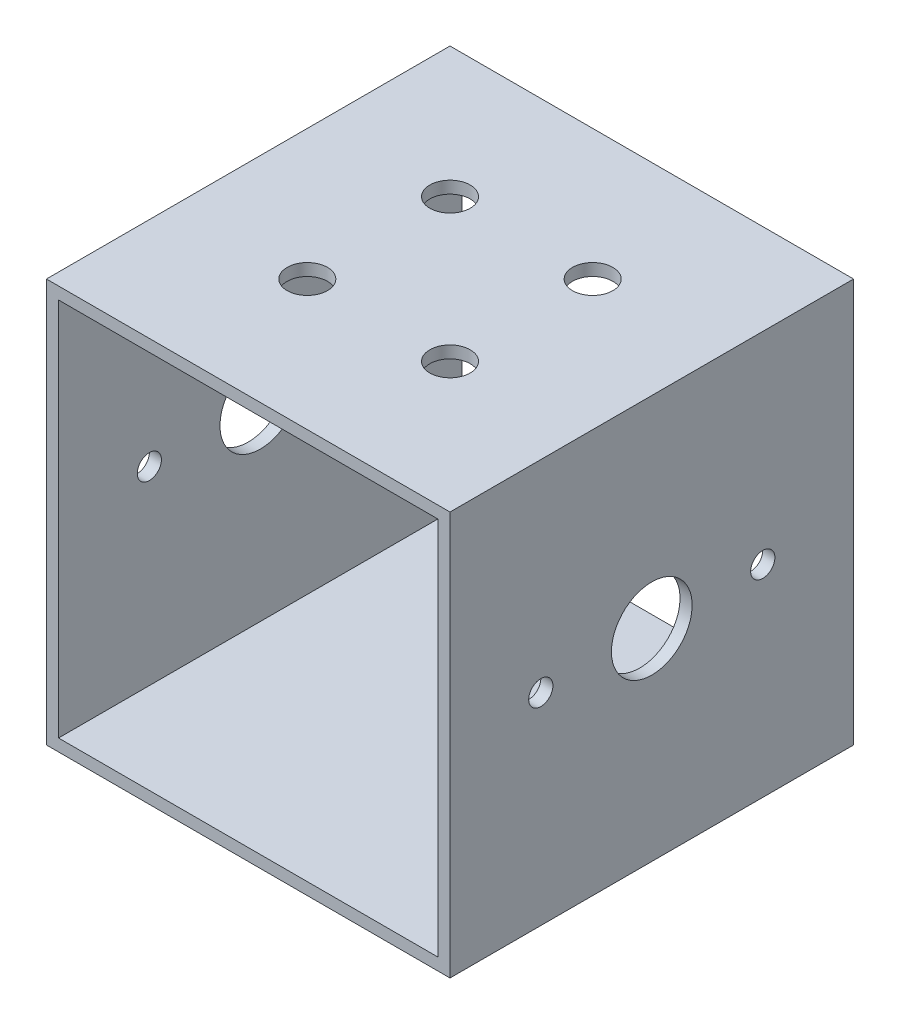
from build123d import *

# Parameters (mm, degrees)
ESBO_O1_W                  = 50
ESBO_O1_H                  = 50
ESBO_O1_W_2                = 47
ESBO_O1_H_2                = 47
RESSALTO_EXTRUS_O1_DEPTH   = 50
ESBO_O3_R                  = 5
CORTE_EXTRUS_O1_DEPTH      = 1
CORTE_EXTRUS_O1_DEPTH_BACK = 51
ESBO_O2_R                  = 2.5
CORTE_EXTRUS_O2_DEPTH      = 10
ESBO_O5_R                  = 1.5
CORTE_EXTRUS_O3_DEPTH      = 1
CORTE_EXTRUS_O3_DEPTH_BACK = 51


with BuildPart() as part:
    # Esboço1 → Ressalto-extrusão1 (new body)
    with BuildSketch(Plane.XY):
        Rectangle(ESBO_O1_W, ESBO_O1_H)
        Rectangle(ESBO_O1_W_2, ESBO_O1_H_2, mode=Mode.SUBTRACT)
    extrude(amount=RESSALTO_EXTRUS_O1_DEPTH)

    # Esboço3 → Corte-extrusão1 (cut, two sides)
    with BuildSketch(Plane(origin=(25, 0, 0), x_dir=(0, 0, -1), z_dir=(1, 0, 0))) as corte_extrus_o1_sk:
        with Locations((-25, 0)):
            Circle(ESBO_O3_R)
    extrude(amount=CORTE_EXTRUS_O1_DEPTH, mode=Mode.SUBTRACT)
    extrude(corte_extrus_o1_sk.sketch, amount=-CORTE_EXTRUS_O1_DEPTH_BACK, mode=Mode.SUBTRACT)

    # Esboço2 → Corte-extrusão2 (cut)
    with BuildSketch(Plane(origin=(0, 25, 0), x_dir=(1, 0, 0), z_dir=(0, 1, 0))):
        with Locations((-8.838834765, -16.161165235)):
            Circle(ESBO_O2_R)
        with Locations((8.838834765, -16.161165235)):
            Circle(ESBO_O2_R)
        with Locations((-8.838834765, -33.838834765)):
            Circle(ESBO_O2_R)
        with Locations((8.838834765, -33.838834765)):
            Circle(ESBO_O2_R)
    extrude(amount=-CORTE_EXTRUS_O2_DEPTH, mode=Mode.SUBTRACT)

    # Esboço5 → Corte-extrusão3 (cut, two sides)
    with BuildSketch(Plane(origin=(25, 0, 0), x_dir=(0, 0, -1), z_dir=(1, 0, 0))) as corte_extrus_o3_sk:
        with Locations((-11.25, 0)):
            Circle(ESBO_O5_R)
        with Locations((-38.75, 0)):
            Circle(ESBO_O5_R)
    extrude(amount=CORTE_EXTRUS_O3_DEPTH, mode=Mode.SUBTRACT)
    extrude(corte_extrus_o3_sk.sketch, amount=-CORTE_EXTRUS_O3_DEPTH_BACK, mode=Mode.SUBTRACT)


solid = part.part
